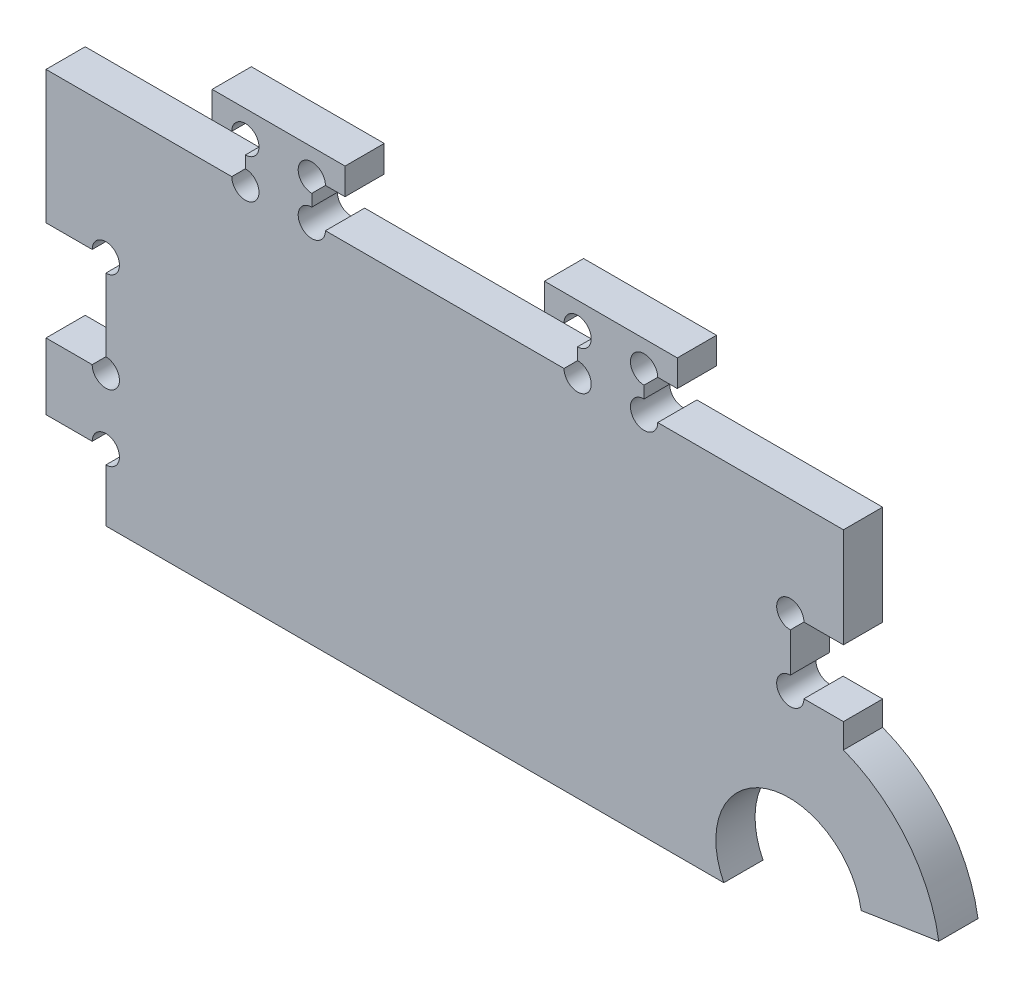
from build123d import *

# Parameters (mm, degrees)
BOSS_EXTRUDE1_DEPTH = 5.9
SKETCH2_W           = 8
SKETCH2_H           = 55
BOSS_EXTRUDE2_DEPTH = 5.9
SKETCH3_W           = 9
SKETCH3_H           = 15
SKETCH3_W_2         = 8
SKETCH3_H_2         = 10
CUT_EXTRUDE1_DEPTH  = 6.9
BOSS_EXTRUDE3_DEPTH = 5.9
CUT_EXTRUDE2_REACH  = 7.9
SKETCH5_R           = 2.05


with BuildPart() as part:
    # Sketch1 → Boss-Extrude1 (new body)
    with BuildSketch(Plane.XY):
        with BuildLine():
            ThreePointArc((97.061822228, 90.695765473), (82.799132124, 99.447826237), (76.396720763, 83.987165662))
            Line((76.396720763, 83.987165662), (-17.603279237, 83.987165662))
            Line((-17.603279237, 83.987165662), (-17.603279237, 138.987165662))
            Line((-17.603279237, 138.987165662), (94.396720763, 138.987165662))
            Line((94.396720763, 138.987165662), (94.396720763, 110.289306386))
            ThreePointArc((94.396720763, 110.289306386), (103.949970876, 103.334562845), (108.745956392, 92.534953205))
            Line((108.745956392, 92.534953205), (97.061822228, 90.695765473))
        make_face()
    extrude(amount=BOSS_EXTRUDE1_DEPTH)

    # Sketch2 → Boss-Extrude2 (add)
    with BuildSketch(Plane.XY.offset(5.9)):
        with Locations((-21.603279237, 111.487165662)):
            Rectangle(SKETCH2_W, SKETCH2_H)
    extrude(amount=-BOSS_EXTRUDE2_DEPTH)

    # Sketch3 → Cut-Extrude1 (cut, through all)
    with BuildSketch(Plane.XY.offset(5.9)):
        with Locations((-21.103279237, 111.487165662)):
            Rectangle(SKETCH3_W, SKETCH3_H)
        with Locations((90.396720763, 118.987165662)):
            Rectangle(SKETCH3_W_2, SKETCH3_H_2)
        with Locations((-21.103279237, 88.987165662)):
            Rectangle(SKETCH3_W, SKETCH3_H_2)
    extrude(amount=-CUT_EXTRUDE1_DEPTH, mode=Mode.SUBTRACT)

    # Sketch4 → Boss-Extrude3 (add)
    with BuildSketch(Plane.XY.offset(5.9)):
        Polygon((4.396720763, 138.987165662), (4.396720763, 144.887165662), (-0.603279237, 144.887165662), (-0.603279237, 148.887165662), (19.396720763, 148.887165662), (19.396720763, 144.887165662), (14.396720763, 144.887165662), (14.396720763, 138.987165662), align=None)
        Polygon((49.396720763, 144.887165662), (49.396720763, 148.887165662), (69.396720763, 148.887165662), (69.396720763, 144.887165662), (64.396720763, 144.887165662), (64.396720763, 138.987165662), (54.396720763, 138.987165662), (54.396720763, 144.887165662), align=None)
    extrude(amount=-BOSS_EXTRUDE3_DEPTH)

    # Sketch5 → Cut-Extrude2 (cut, up to next)
    with BuildSketch(Plane.XY.offset(5.9), mode=Mode.PRIVATE) as cut_extrude2_sk1:
        with Locations((-16.603279237, 93.987165662)):
            Circle(SKETCH5_R)
    cut_extrude2_tool1 = extrude(cut_extrude2_sk1.sketch, amount=-CUT_EXTRUDE2_REACH, mode=Mode.PRIVATE) & part.part
    add(cut_extrude2_tool1.solids().sort_by_distance((-16.603279, 93.987166, 5.9))[0], mode=Mode.SUBTRACT)
    # Sketch5 → Cut-Extrude2 (cut, up to next)
    with BuildSketch(Plane.XY.offset(5.9), mode=Mode.PRIVATE) as cut_extrude2_sk2:
        with Locations((-16.603279237, 103.987165662)):
            Circle(SKETCH5_R)
    cut_extrude2_tool2 = extrude(cut_extrude2_sk2.sketch, amount=-CUT_EXTRUDE2_REACH, mode=Mode.PRIVATE) & part.part
    add(cut_extrude2_tool2.solids().sort_by_distance((-16.603279, 103.987166, 5.9))[0], mode=Mode.SUBTRACT)
    # Sketch5 → Cut-Extrude2 (cut, up to next)
    with BuildSketch(Plane.XY.offset(5.9), mode=Mode.PRIVATE) as cut_extrude2_sk3:
        with Locations((-16.603279237, 118.987165662)):
            Circle(SKETCH5_R)
    cut_extrude2_tool3 = extrude(cut_extrude2_sk3.sketch, amount=-CUT_EXTRUDE2_REACH, mode=Mode.PRIVATE) & part.part
    add(cut_extrude2_tool3.solids().sort_by_distance((-16.603279, 118.987166, 5.9))[0], mode=Mode.SUBTRACT)
    # Sketch5 → Cut-Extrude2 (cut, up to next)
    with BuildSketch(Plane.XY.offset(5.9), mode=Mode.PRIVATE) as cut_extrude2_sk4:
        with Locations((4.396720763, 138.987165662)):
            Circle(SKETCH5_R)
    cut_extrude2_tool4 = extrude(cut_extrude2_sk4.sketch, amount=-CUT_EXTRUDE2_REACH, mode=Mode.PRIVATE) & part.part
    add(cut_extrude2_tool4.solids().sort_by_distance((4.396721, 138.987166, 5.9))[0], mode=Mode.SUBTRACT)
    # Sketch5 → Cut-Extrude2 (cut, up to next)
    with BuildSketch(Plane.XY.offset(5.9), mode=Mode.PRIVATE) as cut_extrude2_sk5:
        with Locations((14.396720763, 138.987165662)):
            Circle(SKETCH5_R)
    cut_extrude2_tool5 = extrude(cut_extrude2_sk5.sketch, amount=-CUT_EXTRUDE2_REACH, mode=Mode.PRIVATE) & part.part
    add(cut_extrude2_tool5.solids().sort_by_distance((14.396721, 138.987166, 5.9))[0], mode=Mode.SUBTRACT)
    # Sketch5 → Cut-Extrude2 (cut, up to next)
    with BuildSketch(Plane.XY.offset(5.9), mode=Mode.PRIVATE) as cut_extrude2_sk6:
        with Locations((14.396720763, 144.887165662)):
            Circle(SKETCH5_R)
    cut_extrude2_tool6 = extrude(cut_extrude2_sk6.sketch, amount=-CUT_EXTRUDE2_REACH, mode=Mode.PRIVATE) & part.part
    add(cut_extrude2_tool6.solids().sort_by_distance((14.396721, 144.887166, 5.9))[0], mode=Mode.SUBTRACT)
    # Sketch5 → Cut-Extrude2 (cut, up to next)
    with BuildSketch(Plane.XY.offset(5.9), mode=Mode.PRIVATE) as cut_extrude2_sk7:
        with Locations((4.396720763, 144.887165662)):
            Circle(SKETCH5_R)
    cut_extrude2_tool7 = extrude(cut_extrude2_sk7.sketch, amount=-CUT_EXTRUDE2_REACH, mode=Mode.PRIVATE) & part.part
    add(cut_extrude2_tool7.solids().sort_by_distance((4.396721, 144.887166, 5.9))[0], mode=Mode.SUBTRACT)
    # Sketch5 → Cut-Extrude2 (cut, up to next)
    with BuildSketch(Plane.XY.offset(5.9), mode=Mode.PRIVATE) as cut_extrude2_sk8:
        with Locations((54.396720763, 144.887165662)):
            Circle(SKETCH5_R)
    cut_extrude2_tool8 = extrude(cut_extrude2_sk8.sketch, amount=-CUT_EXTRUDE2_REACH, mode=Mode.PRIVATE) & part.part
    add(cut_extrude2_tool8.solids().sort_by_distance((54.396721, 144.887166, 5.9))[0], mode=Mode.SUBTRACT)
    # Sketch5 → Cut-Extrude2 (cut, up to next)
    with BuildSketch(Plane.XY.offset(5.9), mode=Mode.PRIVATE) as cut_extrude2_sk9:
        with Locations((64.396720763, 144.887165662)):
            Circle(SKETCH5_R)
    cut_extrude2_tool9 = extrude(cut_extrude2_sk9.sketch, amount=-CUT_EXTRUDE2_REACH, mode=Mode.PRIVATE) & part.part
    add(cut_extrude2_tool9.solids().sort_by_distance((64.396721, 144.887166, 5.9))[0], mode=Mode.SUBTRACT)
    # Sketch5 → Cut-Extrude2 (cut, up to next)
    with BuildSketch(Plane.XY.offset(5.9), mode=Mode.PRIVATE) as cut_extrude2_sk10:
        with Locations((64.396720763, 138.987165662)):
            Circle(SKETCH5_R)
    cut_extrude2_tool10 = extrude(cut_extrude2_sk10.sketch, amount=-CUT_EXTRUDE2_REACH, mode=Mode.PRIVATE) & part.part
    add(cut_extrude2_tool10.solids().sort_by_distance((64.396721, 138.987166, 5.9))[0], mode=Mode.SUBTRACT)
    # Sketch5 → Cut-Extrude2 (cut, up to next)
    with BuildSketch(Plane.XY.offset(5.9), mode=Mode.PRIVATE) as cut_extrude2_sk11:
        with Locations((54.396720763, 138.987165662)):
            Circle(SKETCH5_R)
    cut_extrude2_tool11 = extrude(cut_extrude2_sk11.sketch, amount=-CUT_EXTRUDE2_REACH, mode=Mode.PRIVATE) & part.part
    add(cut_extrude2_tool11.solids().sort_by_distance((54.396721, 138.987166, 5.9))[0], mode=Mode.SUBTRACT)
    # Sketch5 → Cut-Extrude2 (cut, up to next)
    with BuildSketch(Plane.XY.offset(5.9), mode=Mode.PRIVATE) as cut_extrude2_sk12:
        with Locations((86.396720763, 123.987165662)):
            Circle(SKETCH5_R)
    cut_extrude2_tool12 = extrude(cut_extrude2_sk12.sketch, amount=-CUT_EXTRUDE2_REACH, mode=Mode.PRIVATE) & part.part
    add(cut_extrude2_tool12.solids().sort_by_distance((86.396721, 123.987166, 5.9))[0], mode=Mode.SUBTRACT)
    # Sketch5 → Cut-Extrude2 (cut, up to next)
    with BuildSketch(Plane.XY.offset(5.9), mode=Mode.PRIVATE) as cut_extrude2_sk13:
        with Locations((86.396720763, 113.987165662)):
            Circle(SKETCH5_R)
    cut_extrude2_tool13 = extrude(cut_extrude2_sk13.sketch, amount=-CUT_EXTRUDE2_REACH, mode=Mode.PRIVATE) & part.part
    add(cut_extrude2_tool13.solids().sort_by_distance((86.396721, 113.987166, 5.9))[0], mode=Mode.SUBTRACT)


solid = part.part
